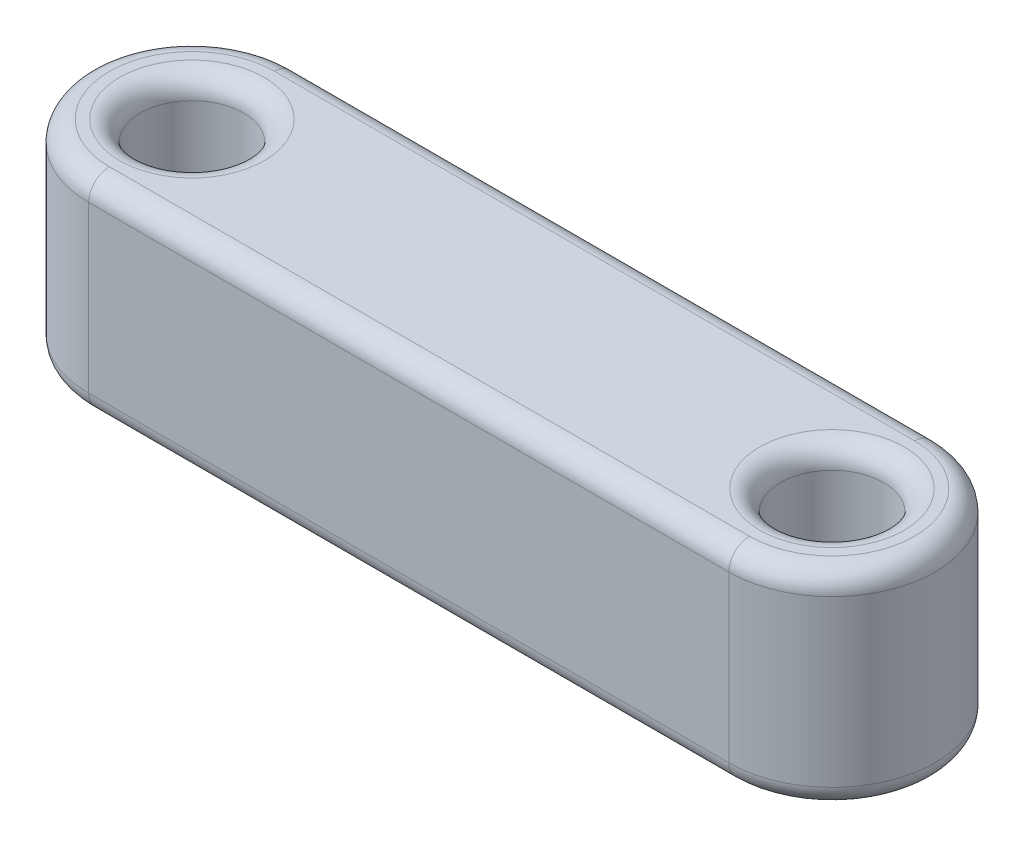
from build123d import *

# Parameters (mm, degrees)
SKETCH1_R           = 2.5
BOSS_EXTRUDE1_DEPTH = 10
FILLET1_R           = 1


with BuildPart() as part:
    # Sketch1 → Boss-Extrude1 (new body)
    with BuildSketch(Plane(origin=(0, 0, 0), x_dir=(1, 0, 0), z_dir=(0, 1, 0))):
        with BuildLine():
            Line((0, 5), (31, 5))
            ThreePointArc((31, 5), (36, 0), (31, -5))
            Line((31, -5), (0, -5))
            ThreePointArc((0, -5), (-5, 0), (0, 5))
        make_face()
        Circle(SKETCH1_R, mode=Mode.SUBTRACT)
        with Locations((31, 0)):
            Circle(SKETCH1_R, mode=Mode.SUBTRACT)
    extrude(amount=BOSS_EXTRUDE1_DEPTH)

    # Fillet1
    fillet1_edges = [part.edges().sort_by_distance(p)[0] for p in [
        (-2.5, 0, 0),
        (-2.5, 10, 0),
        (36, 10, 0),
        (28.5, 0, 0),
        (28.5, 10, 0),
        (15.5, 10, -5),
        (-5, 10, 0),
        (15.5, 0, -5),
        (36, 0, 0),
        (15.5, 0, 5),
        (-5, 0, 0),
        (15.5, 10, 5),
    ]]
    fillet(fillet1_edges, radius=FILLET1_R)


solid = part.part
